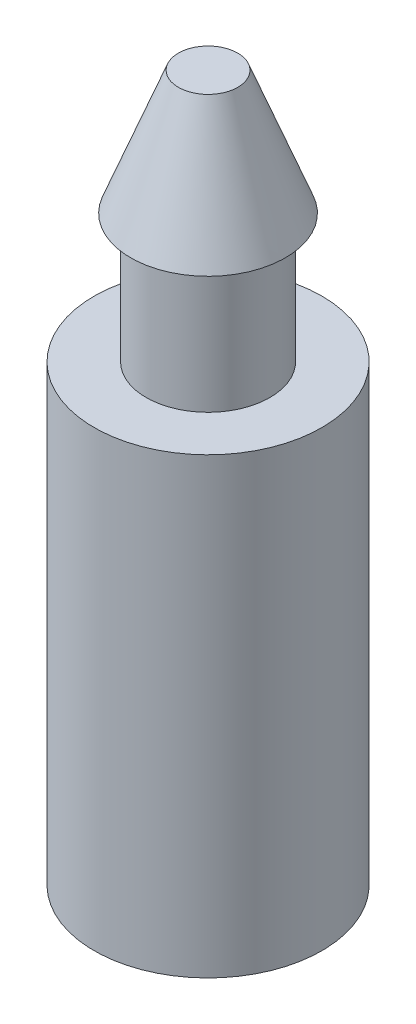
from build123d import *


with BuildPart() as part:
    # Sketch1 → Revolve1 (revolve)
    with BuildSketch(Plane.XY):
        Polygon((0, 0), (0, 7.239), (0.304382523, 7.239), (0.79375, 5.969), (0.635, 5.969), (0.635, 4.6482), (1.1684, 4.6482), (1.1684, 0), align=None)
    revolve(axis=Axis((0, 0, 0), (0, 1, 0)))


solid = part.part
